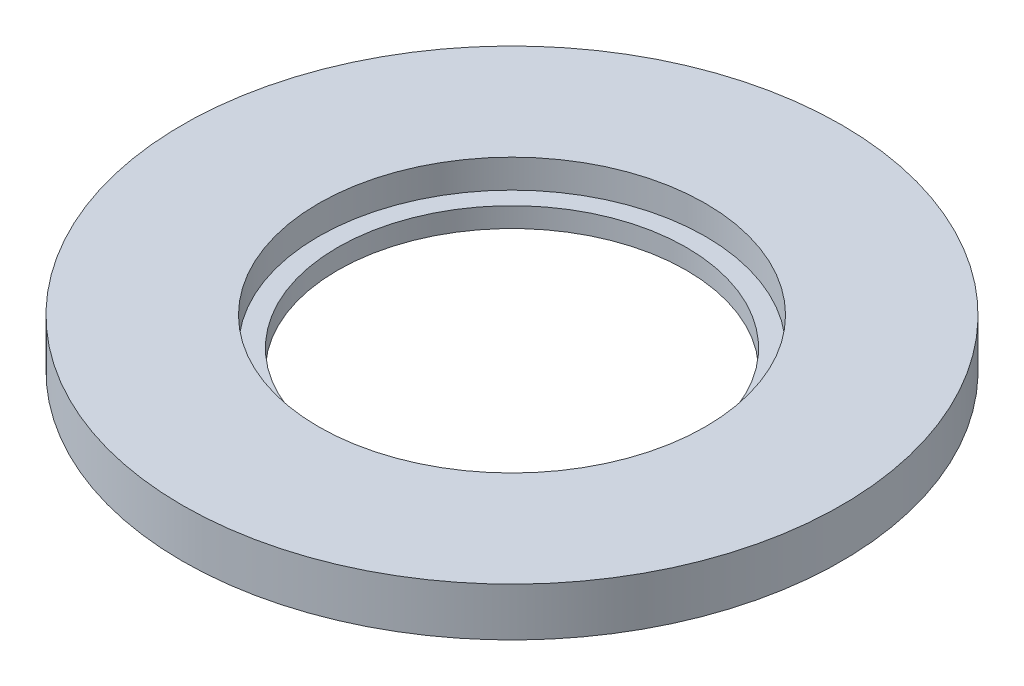
from build123d import *

# Parameters (mm, degrees)
SKETCH15_R          = 86.55
SKETCH15_R_2        = 82.55
BOSS_EXTRUDE2_DEPTH = 12.7


with BuildPart() as part:
    # Sketch2 → Revolve1 (revolve)
    with BuildSketch(Plane(origin=(0, 0, 0), x_dir=(0, 0, -1), z_dir=(1, 0, 0))):
        Polygon((-45.8, 0), (-82.55, 0), (-82.55, 12.7), (-50.8, 12.7), (-50.8, 5.2), (-45.8, 5.2), align=None)
    revolve(axis=Axis((0, -0.5, 0), (0, 1, 0)))

    # Sketch15 → Boss-Extrude2 (add)
    with BuildSketch(Plane.XZ):
        Circle(SKETCH15_R)
        Circle(SKETCH15_R_2, mode=Mode.SUBTRACT)
    extrude(amount=-BOSS_EXTRUDE2_DEPTH)


solid = part.part
